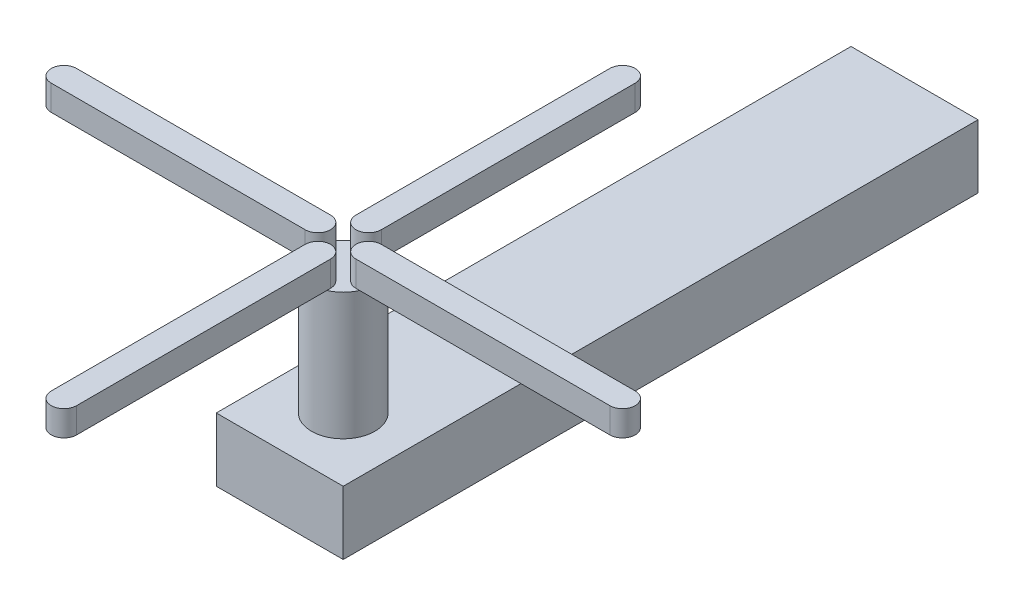
from build123d import *

# Parameters (mm, degrees)
SKETCH1_W           = 25.4
SKETCH1_H           = 12.7
BOSS_EXTRUDE1_DEPTH = 127
SKETCH2_R           = 6.35
BOSS_EXTRUDE2_DEPTH = 25.4
BOSS_EXTRUDE3_DEPTH = 5.08


with BuildPart() as part:
    # Sketch1 → Boss-Extrude1 (new body)
    with BuildSketch(Plane.XY):
        Rectangle(SKETCH1_W, SKETCH1_H)
    extrude(amount=BOSS_EXTRUDE1_DEPTH)

    # Sketch2 → Boss-Extrude2 (add)
    with BuildSketch(Plane(origin=(0, 6.35, 0), x_dir=(1, 0, 0), z_dir=(0, 1, 0))):
        with Locations((0, -114.3)):
            Circle(SKETCH2_R)
    extrude(amount=BOSS_EXTRUDE2_DEPTH)

    # Sketch3 → Boss-Extrude3 (add)
    with BuildSketch(Plane(origin=(0, 31.75, 0), x_dir=(1, 0, 0), z_dir=(0, 1, 0))):
        with BuildLine():
            Line((5.08, -111.76), (55.88, -111.76))
            ThreePointArc((55.88, -111.76), (58.42, -114.3), (55.88, -116.84))
            Line((55.88, -116.84), (5.08, -116.84))
            ThreePointArc((5.08, -116.84), (2.54, -114.3), (5.08, -111.76))
        make_face()
        with BuildLine():
            Line((-2.54, -119.38), (-2.54, -170.18))
            ThreePointArc((-2.54, -170.18), (0, -172.72), (2.54, -170.18))
            Line((2.54, -170.18), (2.54, -119.38))
            ThreePointArc((2.54, -119.38), (0, -116.84), (-2.54, -119.38))
        make_face()
        with BuildLine():
            Line((-5.08, -111.76), (-55.88, -111.76))
            ThreePointArc((-55.88, -111.76), (-58.42, -114.3), (-55.88, -116.84))
            Line((-55.88, -116.84), (-5.08, -116.84))
            ThreePointArc((-5.08, -116.84), (-2.54, -114.3), (-5.08, -111.76))
        make_face()
        with BuildLine():
            Line((2.54, -109.22), (2.54, -58.42))
            ThreePointArc((2.54, -58.42), (0, -55.88), (-2.54, -58.42))
            Line((-2.54, -58.42), (-2.54, -109.22))
            ThreePointArc((-2.54, -109.22), (0, -111.76), (2.54, -109.22))
        make_face()
    extrude(amount=BOSS_EXTRUDE3_DEPTH)


solid = part.part
